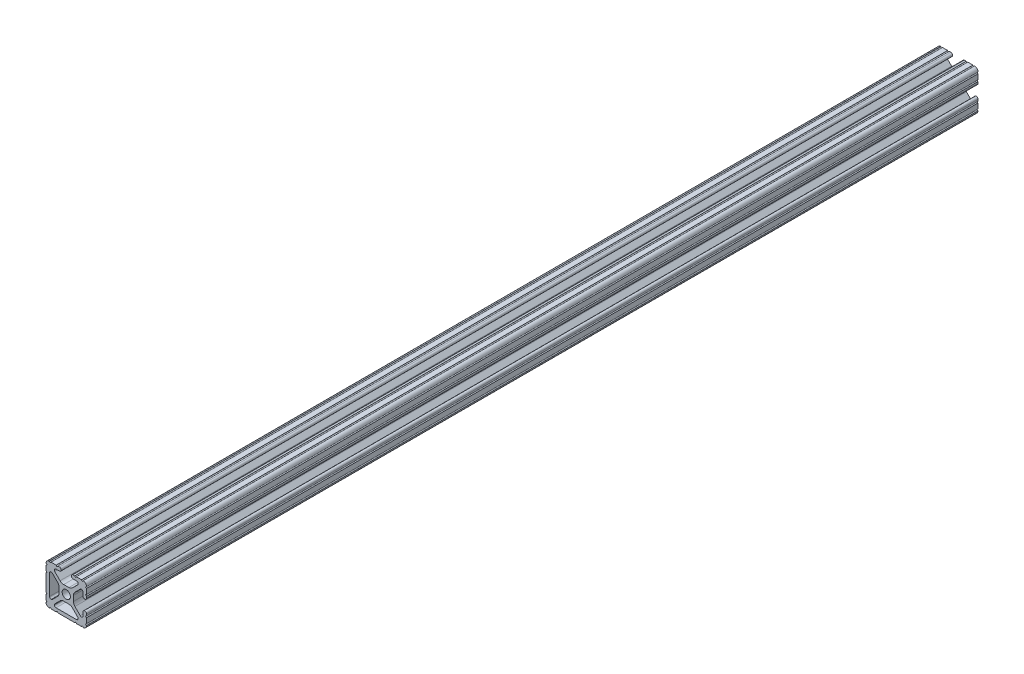
from build123d import *

# Parameters (mm, degrees)
SKETCH1_R           = 2.6035
BOSS_EXTRUDE1_DEPTH = 558.8


with BuildPart() as part:
    # Sketch1 → Boss-Extrude1 (new body)
    with BuildSketch(Plane(origin=(0, 0, -558.8), x_dir=(-1, 0, 0), z_dir=(0, 0, -1))):
        with BuildLine():
            Line((12.699999967, -9.5504), (12.699999967, -6.3246))
            ThreePointArc((12.699999967, -6.3246), (12.191999967, -5.8166), (12.699999967, -5.3086))
            Line((12.699999967, -5.3086), (12.699999967, 5.3086))
            ThreePointArc((12.699999967, 5.3086), (12.191999967, 5.8166), (12.699999967, 6.3246))
            Line((12.699999967, 6.3246), (12.699999967, 9.550399967))
            ThreePointArc((12.699999967, 9.550399967), (12.191999934, 10.058400016), (12.699999999, 10.566400033))
            ThreePointArc((12.699999999, 10.566400033), (12.082677404, 12.082677438), (10.566399999, 12.700000033))
            ThreePointArc((10.566399999, 12.700000033), (10.058400007, 12.192000016), (9.550399999, 12.700000016))
            Line((9.550399999, 12.700000016), (6.324599999, 12.700000016))
            ThreePointArc((6.324599999, 12.700000016), (5.816599999, 12.192000016), (5.308599999, 12.700000016))
            Line((5.308599999, 12.700000016), (4.302307888, 12.700000016))
            ThreePointArc((4.302307888, 12.700000016), (3.197407888, 11.595100016), (4.302307888, 10.490200016))
            Line((4.302307888, 10.490200016), (6.474794464, 10.490200016))
            ThreePointArc((6.474794464, 10.490200016), (7.413456072, 9.863006381), (7.193214956, 8.755779521))
            Line((7.193214956, 8.755779521), (3.875871421, 5.438435986))
            ThreePointArc((3.875871421, 5.438435986), (2.845827288, 4.7501825), (1.63080739, 4.508500016))
            Line((1.63080739, 4.508500016), (-1.630807376, 4.508500016))
            ThreePointArc((-1.630807376, 4.508500016), (-2.845827273, 4.7501825), (-3.875871406, 5.438435986))
            Line((-3.875871406, 5.438435986), (-7.193214947, 8.755779526))
            ThreePointArc((-7.193214947, 8.755779526), (-7.413456062, 9.863006383), (-6.474794457, 10.490200016))
            Line((-6.474794457, 10.490200016), (-4.302307919, 10.490200016))
            ThreePointArc((-4.302307919, 10.490200016), (-3.197407919, 11.595100016), (-4.302307919, 12.700000016))
            Line((-4.302307919, 12.700000016), (-5.308600001, 12.700000016))
            ThreePointArc((-5.308600001, 12.700000016), (-5.816600001, 12.192000016), (-6.324600001, 12.700000016))
            Line((-6.324600001, 12.700000016), (-9.550400001, 12.700000016))
            ThreePointArc((-9.550400001, 12.700000016), (-10.058400001, 12.192000016), (-10.566400001, 12.700000016))
            ThreePointArc((-10.566400001, 12.700000016), (-12.082677418, 12.082677417), (-12.700000017, 10.5664))
            ThreePointArc((-12.700000017, 10.5664), (-12.192, 10.058400008), (-12.7, 9.5504))
            Line((-12.7, 9.5504), (-12.7, 6.3246))
            ThreePointArc((-12.7, 6.3246), (-12.192, 5.8166), (-12.7, 5.3086))
            Line((-12.7, 5.3086), (-12.7, 4.302307889))
            ThreePointArc((-12.7, 4.302307889), (-11.5951, 3.197407889), (-10.4902, 4.302307889))
            Line((-10.4902, 4.302307889), (-10.4902, 6.474794456))
            ThreePointArc((-10.4902, 6.474794456), (-9.863006367, 7.413456061), (-8.75577951, 7.193214945))
            Line((-8.75577951, 7.193214945), (-5.43843597, 3.875871405))
            ThreePointArc((-5.43843597, 3.875871405), (-4.750182484, 2.845827272), (-4.5085, 1.630807374))
            Line((-4.5085, 1.630807374), (-4.5085, -1.630807374))
            ThreePointArc((-4.5085, -1.630807374), (-4.750182484, -2.845827272), (-5.43843597, -3.875871405))
            Line((-5.43843597, -3.875871405), (-8.75577951, -7.193214945))
            ThreePointArc((-8.75577951, -7.193214945), (-9.863006367, -7.413456061), (-10.4902, -6.474794456))
            Line((-10.4902, -6.474794456), (-10.4902, -4.302307918))
            ThreePointArc((-10.4902, -4.302307918), (-11.5951, -3.197407918), (-12.7, -4.302307918))
            Line((-12.7, -4.302307918), (-12.7, -5.3086))
            ThreePointArc((-12.7, -5.3086), (-12.192, -5.8166), (-12.7, -6.3246))
            Line((-12.7, -6.3246), (-12.7, -9.5504))
            ThreePointArc((-12.7, -9.5504), (-12.192, -10.058400008), (-12.700000017, -10.5664))
            ThreePointArc((-12.700000017, -10.5664), (-12.082677422, -12.082677406), (-10.566400017, -12.7))
            ThreePointArc((-10.566400017, -12.7), (-10.058400017, -12.192), (-9.550400017, -12.7))
            Line((-9.550400017, -12.7), (-6.324600017, -12.7))
            ThreePointArc((-6.324600017, -12.7), (-5.816600017, -12.192), (-5.308600017, -12.7))
            Line((-5.308600017, -12.7), (5.308599983, -12.7))
            ThreePointArc((5.308599983, -12.7), (5.816599983, -12.192), (6.324599983, -12.7))
            Line((6.324599983, -12.7), (9.550399983, -12.7))
            ThreePointArc((9.550399983, -12.7), (10.058399983, -12.192), (10.566399983, -12.7))
            ThreePointArc((10.566399983, -12.7), (12.082677389, -12.082677406), (12.699999983, -10.5664))
            ThreePointArc((12.699999983, -10.5664), (12.191999967, -10.058400008), (12.699999967, -9.5504))
        make_face()
        Circle(SKETCH1_R, mode=Mode.SUBTRACT)
        with BuildLine():
            Line((3.875871405, -5.43843597), (7.13192049, -8.694485055))
            ThreePointArc((7.13192049, -8.694485055), (7.35441848, -9.056211656), (7.4295, -9.4742))
            ThreePointArc((7.4295, -9.4742), (7.13192049, -10.19262049), (6.4135, -10.4902))
            Line((6.4135, -10.4902), (-6.4135, -10.4902))
            ThreePointArc((-6.4135, -10.4902), (-7.13192049, -10.19262049), (-7.4295, -9.4742))
            ThreePointArc((-7.4295, -9.4742), (-7.35441848, -9.056211656), (-7.13192049, -8.694485055))
            Line((-7.13192049, -8.694485055), (-3.875871405, -5.43843597))
            ThreePointArc((-3.875871405, -5.43843597), (-2.845827272, -4.750182484), (-1.630807374, -4.5085))
            Line((-1.630807374, -4.5085), (1.630807374, -4.5085))
            ThreePointArc((1.630807374, -4.5085), (2.845827272, -4.750182484), (3.875871405, -5.43843597))
        make_face(mode=Mode.SUBTRACT)
        with BuildLine():
            Line((10.490199999, 6.4135), (10.490199999, -6.413499984))
            ThreePointArc((10.490199999, -6.413499984), (10.192620488, -7.131920474), (9.474199999, -7.429499984))
            ThreePointArc((9.474199999, -7.429499984), (9.056211655, -7.354418464), (8.694485053, -7.131920474))
            Line((8.694485053, -7.131920474), (5.438435968, -3.875871389))
            ThreePointArc((5.438435968, -3.875871389), (4.750182483, -2.845827256), (4.508499999, -1.630807359))
            Line((4.508499999, -1.630807359), (4.508499999, 1.630807373))
            ThreePointArc((4.508499999, 1.630807373), (4.750182483, 2.845827271), (5.438435968, 3.875871403))
            Line((5.438435968, 3.875871403), (8.694485055, 7.13192049))
            ThreePointArc((8.694485055, 7.13192049), (9.056211656, 7.35441848), (9.4742, 7.4295))
            ThreePointArc((9.4742, 7.4295), (10.192620489, 7.131920489), (10.490199999, 6.4135))
        make_face(mode=Mode.SUBTRACT)
    extrude(amount=-BOSS_EXTRUDE1_DEPTH)


solid = part.part
